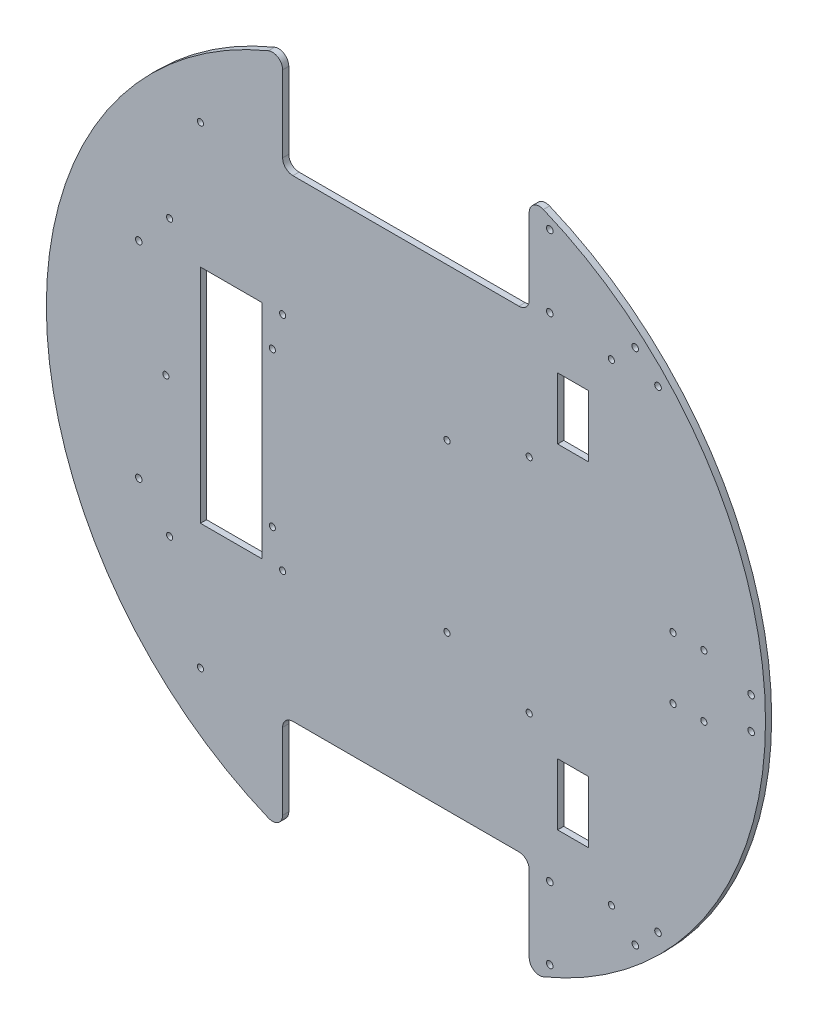
from build123d import *

# Parameters (mm, degrees)
SKETCH_1_R           = 175
EXTRUDE_1_DEPTH      = 3
CUT_EXTRUDE_1_DEPTH  = 3
FILLET_1_R           = 5
FILLET_2_R           = 5
FILLET_3_R           = 5
SKETCH_5_R           = 1.5
CUT_EXTRUDE_4_DEPTH  = 3
SKETCH_6_R           = 1.5
CUT_EXTRUDE_5_DEPTH  = 3
SKETCH_7_W           = 30
SKETCH_7_H           = 108
CUT_EXTRUDE_6_DEPTH  = 3
SKETCH_8_R           = 1.5
CUT_EXTRUDE_7_DEPTH  = 3
SKETCH_9_R           = 1.5
CUT_EXTRUDE_8_DEPTH  = 10
SKETCH_10_R          = 1.6
CUT_EXTRUDE_9_DEPTH  = 10
SKETCH_11_W          = 15
SKETCH_11_H          = 30
CUT_EXTRUDE_10_DEPTH = 10
SKETCH_13_R          = 1.5
CUT_EXTRUDE_12_DEPTH = 4
SKETCH_14_R          = 1.6
CUT_EXTRUDE_14_DEPTH = 4


with BuildPart() as part:
    # ｽｹｯﾁ1 → ﾎﾞｽ - 押し出し1 (new body)
    with BuildSketch(Plane.XY):
        Circle(SKETCH_1_R)
    extrude(amount=EXTRUDE_1_DEPTH)

    # ｽｹｯﾁ2 → ｶｯﾄ - 押し出し1 (cut)
    with BuildSketch(Plane.XY.offset(3)):
        with BuildLine():
            Line((-60, 115), (0, 115))
            Line((0, 115), (0, 175))
            ThreePointArc((0, 175), (-30.465194158, 172.327803749), (-60, 164.392822228))
            Line((-60, 164.392822228), (-60, 115))
        make_face()
        with BuildLine():
            Line((0, 175), (0, 115))
            Line((0, 115), (60, 115))
            Line((60, 115), (60, 164.392822228))
            ThreePointArc((60, 164.392822228), (30.465194158, 172.327803749), (0, 175))
        make_face()
        with BuildLine():
            Line((0, -175), (0, -115))
            Line((0, -115), (-60, -115))
            Line((-60, -115), (-60, -164.392822228))
            ThreePointArc((-60, -164.392822228), (-30.465194158, -172.327803749), (0, -175))
        make_face()
        with BuildLine():
            Line((60, -115), (0, -115))
            Line((0, -115), (0, -175))
            ThreePointArc((0, -175), (30.465194158, -172.327803749), (60, -164.392822228))
            Line((60, -164.392822228), (60, -115))
        make_face()
    extrude(amount=-CUT_EXTRUDE_1_DEPTH, mode=Mode.SUBTRACT)

    # ﾌｨﾚｯﾄ1
    fillet_1_edges = [part.edges().sort_by_distance(p)[0] for p in [
        (-60, 164.392822228, 1.5),
    ]]
    fillet(fillet_1_edges, radius=FILLET_1_R)

    # ﾌｨﾚｯﾄ2
    fillet_2_edges = [part.edges().sort_by_distance(p)[0] for p in [
        (-60, 115, 1.5),
        (60, 164.392822228, 1.5),
        (60, 115, 1.5),
    ]]
    fillet(fillet_2_edges, radius=FILLET_2_R)

    # ﾌｨﾚｯﾄ3
    fillet_3_edges = [part.edges().sort_by_distance(p)[0] for p in [
        (-60, -115, 1.5),
        (60, -115, 1.5),
        (60, -164.392822228, 1.5),
        (-60, -164.392822228, 1.5),
    ]]
    fillet(fillet_3_edges, radius=FILLET_3_R)

    # ｽｹｯﾁ5 → ｶｯﾄ - 押し出し4 (cut)
    with BuildSketch(Plane.XY.offset(3)):
        with Locations((-100, -115)):
            Circle(SKETCH_5_R)
        with Locations((100, -115)):
            Circle(SKETCH_5_R)
        with Locations((100, 115)):
            Circle(SKETCH_5_R)
        with Locations((-100, 115)):
            Circle(SKETCH_5_R)
    extrude(amount=-CUT_EXTRUDE_4_DEPTH, mode=Mode.SUBTRACT)

    # ｽｹｯﾁ6 → ｶｯﾄ - 押し出し5 (cut)
    with BuildSketch(Plane.XY.offset(3)):
        with Locations((-60, 54)):
            Circle(SKETCH_6_R)
        with Locations((60, 54)):
            Circle(SKETCH_6_R)
        with Locations((-60, -54)):
            Circle(SKETCH_6_R)
        with Locations((60, -54)):
            Circle(SKETCH_6_R)
    extrude(amount=-CUT_EXTRUDE_5_DEPTH, mode=Mode.SUBTRACT)

    # ｽｹｯﾁ7 → ｶｯﾄ - 押し出し6 (cut)
    with BuildSketch(Plane.XY.offset(3)):
        with Locations((-85, 0)):
            Rectangle(SKETCH_7_W, SKETCH_7_H)
    extrude(amount=-CUT_EXTRUDE_6_DEPTH, mode=Mode.SUBTRACT)

    # ｽｹｯﾁ8 → ｶｯﾄ - 押し出し7 (cut)
    with BuildSketch(Plane.XY.offset(3)):
        with Locations((-115, -67)):
            Circle(SKETCH_8_R)
        with Locations((-116.822468618, 0)):
            Circle(SKETCH_8_R)
        with Locations((-115, 67)):
            Circle(SKETCH_8_R)
    extrude(amount=-CUT_EXTRUDE_7_DEPTH, mode=Mode.SUBTRACT)

    # ｽｹｯﾁ9 → ｶｯﾄ - 押し出し8 (cut)
    with BuildSketch(Plane.XY.offset(3)):
        with Locations((-65, 37)):
            Circle(SKETCH_9_R)
        with Locations((20, 41)):
            Circle(SKETCH_9_R)
        with Locations((-65, -38)):
            Circle(SKETCH_9_R)
        with Locations((20, -40)):
            Circle(SKETCH_9_R)
    extrude(amount=-CUT_EXTRUDE_8_DEPTH, mode=Mode.SUBTRACT)

    # ｽｹｯﾁ10 → ｶｯﾄ - 押し出し9 (cut)
    with BuildSketch(Plane.XY.offset(3)):
        with Locations((111.643659725, -125.921059639)):
            Circle(SKETCH_10_R)
        with Locations((122.679794489, -115.037952538)):
            Circle(SKETCH_10_R)
        with Locations((168, 7.75)):
            Circle(SKETCH_10_R)
        with Locations((168, -7.75)):
            Circle(SKETCH_10_R)
        with Locations((111.56768007, 125.844011632)):
            Circle(SKETCH_10_R)
        with Locations((122.679794489, 115.037952538)):
            Circle(SKETCH_10_R)
    extrude(amount=-CUT_EXTRUDE_9_DEPTH, mode=Mode.SUBTRACT)

    # ｽｹｯﾁ11 → ｶｯﾄ - 押し出し10 (cut)
    with BuildSketch(Plane.XY.offset(3)):
        with Locations((81.317279836, 81.317279836)):
            Rectangle(SKETCH_11_W, SKETCH_11_H)
        with Locations((81.317279836, -81.317279836)):
            Rectangle(SKETCH_11_W, SKETCH_11_H)
    extrude(amount=-CUT_EXTRUDE_10_DEPTH, mode=Mode.SUBTRACT)

    # ｽｹｯﾁ13 → ｶｯﾄ - 押し出し12 (cut, through all)
    with BuildSketch(Plane.XY.offset(3)):
        with Locations((130, 15)):
            Circle(SKETCH_13_R)
        with Locations((145, 15)):
            Circle(SKETCH_13_R)
        with Locations((130, -15)):
            Circle(SKETCH_13_R)
        with Locations((145, -15)):
            Circle(SKETCH_13_R)
    extrude(amount=-CUT_EXTRUDE_12_DEPTH, mode=Mode.SUBTRACT)

    # ｽｹｯﾁ14 → ｶｯﾄ - 押し出し14 (cut, through all)
    with BuildSketch(Plane.XY.offset(3)):
        with Locations((70, 119.792059696)):
            Circle(SKETCH_14_R)
        with Locations((70, 154.792059696)):
            Circle(SKETCH_14_R)
        with Locations((70, -120)):
            Circle(SKETCH_14_R)
        with Locations((70, -155)):
            Circle(SKETCH_14_R)
        with Locations((-130, 50.05)):
            Circle(SKETCH_14_R)
        with Locations((-130, -50.05)):
            Circle(SKETCH_14_R)
    extrude(amount=-CUT_EXTRUDE_14_DEPTH, mode=Mode.SUBTRACT)


solid = part.part
